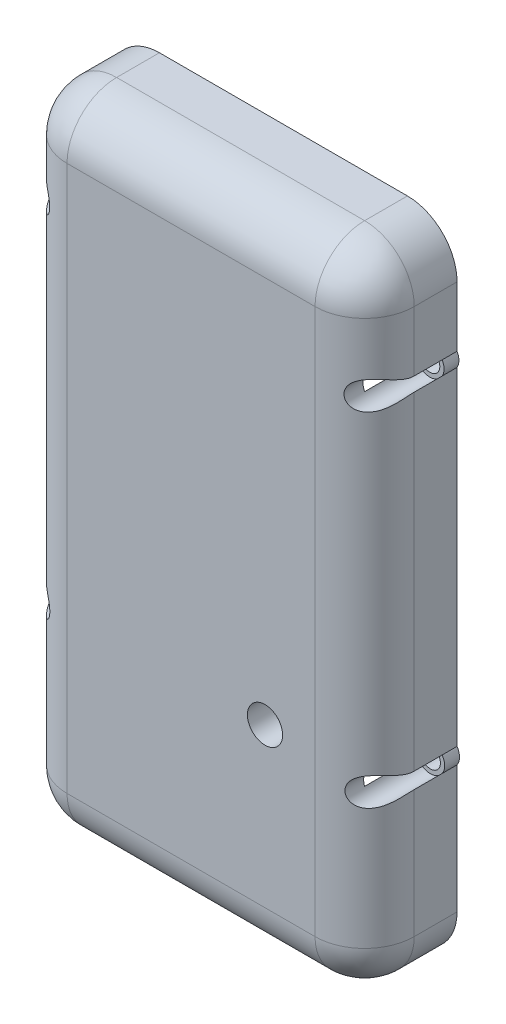
from build123d import *

# Parameters (mm, degrees)
SKETCH1_W           = 70
SKETCH1_H           = 130
BOSS_EXTRUDE1_DEPTH = 18.631112222
SHELL1_T            = -5
FILLET1_R           = 10
FILLET2_R           = 10
FILLET4_R           = 10
FILLET6_R           = 10
SKETCH2_R           = 3.55
CUT_EXTRUDE1_DEPTH  = 26
SKETCH3_W           = 14.110384164
SKETCH3_H           = 8.306919709
CUT_EXTRUDE4_DEPTH  = 30
SKETCH4_R           = 2.85
CUT_EXTRUDE5_DEPTH  = 24
SKETCH5_R           = 2.85
SKETCH5_R_2         = 2
BOSS_EXTRUDE2_DEPTH = 3


with BuildPart() as part:
    # Sketch1 → Boss-Extrude1 (new body)
    with BuildSketch(Plane.XY):
        with Locations((8.736165571, -22.960828507)):
            Rectangle(SKETCH1_W, SKETCH1_H)
    extrude(amount=BOSS_EXTRUDE1_DEPTH)

    # Shell1
    shell1_openings = [part.faces().sort_by_distance(p)[0] for p in [
        (8.736165571, -22.960828507, 0),
    ]]
    offset(amount=SHELL1_T, openings=shell1_openings, kind=Kind.INTERSECTION)

    # Fillet1
    fillet1_edges = [part.edges().sort_by_distance(p)[0] for p in [
        (-26.263834429, -22.960828507, 18.631112222),
    ]]
    fillet(fillet1_edges, radius=FILLET1_R)

    # Fillet2
    fillet2_edges = [part.edges().sort_by_distance(p)[0] for p in [
        (43.736165571, -22.960828507, 18.631112222),
    ]]
    fillet(fillet2_edges, radius=FILLET2_R)

    # Fillet4
    fillet4_edges = [part.edges().sort_by_distance(p)[0] for p in [
        (-26.263834429, 42.039171493, 4.315556111),
        (-23.334902241, 42.039171493, 15.702180034),
        (8.736165571, 42.039171493, 18.631112222),
        (43.736165571, 42.039171493, 4.315556111),
        (40.807233383, 42.039171493, 15.702180034),
    ]]
    fillet(fillet4_edges, radius=FILLET4_R)

    # Fillet6
    fillet6_edges = [part.edges().sort_by_distance(p)[0] for p in [
        (8.736165571, -87.960828507, 18.631112222),
        (-26.263834429, -87.960828507, 4.315556111),
        (-23.334902241, -87.960828507, 15.702180034),
        (43.736165571, -87.960828507, 4.315556111),
        (40.807233383, -87.960828507, 15.702180034),
    ]]
    fillet(fillet6_edges, radius=FILLET6_R)

    # Sketch2 → Cut-Extrude1 (cut)
    with BuildSketch(Plane.XY.offset(7.783233926)):
        with Locations((23.655578881, -46.034025118)):
            Circle(SKETCH2_R)
    extrude(amount=CUT_EXTRUDE1_DEPTH, mode=Mode.SUBTRACT)

    # Sketch3 → Cut-Extrude4 (cut)
    with BuildSketch(Plane(origin=(1.2837e-05, -73.41928233, 3.209e-06), x_dir=(-1, -1.75e-07, 0), z_dir=(1.75e-07, -1, 4.4e-08))):
        with Locations((-5.237013871, -5.398091498)):
            Rectangle(SKETCH3_W, SKETCH3_H)
    extrude(amount=CUT_EXTRUDE4_DEPTH, mode=Mode.SUBTRACT)

    # Sketch4 → Cut-Extrude5 (cut)
    with BuildSketch(Plane.XY):
        with Locations((41.386116272, -50.678340094)):
            Circle(SKETCH4_R)
        with Locations((41.259820466, 18.511183857)):
            Circle(SKETCH4_R)
        with Locations((-23.693524603, -49.042382464)):
            Circle(SKETCH4_R)
        with Locations((-23.751261028, 21.516382028)):
            Circle(SKETCH4_R)
    extrude(amount=CUT_EXTRUDE5_DEPTH, mode=Mode.SUBTRACT)

    # Sketch5 → Boss-Extrude2 (add)
    with BuildSketch(Plane.XY):
        with Locations((-23.751261028, 21.516382028)):
            Circle(SKETCH5_R)
        with Locations((-23.751261028, 21.516382028)):
            Circle(SKETCH5_R_2, mode=Mode.SUBTRACT)
        with Locations((41.259820466, 18.511183857)):
            Circle(SKETCH5_R)
        with Locations((41.259820466, 18.511183857)):
            Circle(SKETCH5_R_2, mode=Mode.SUBTRACT)
        with Locations((41.386116272, -50.678340094)):
            Circle(SKETCH5_R)
        with Locations((41.386116272, -50.678340094)):
            Circle(SKETCH5_R_2, mode=Mode.SUBTRACT)
        with Locations((-23.693524603, -49.042382464)):
            Circle(SKETCH5_R)
        with Locations((-23.693524603, -49.042382464)):
            Circle(SKETCH5_R_2, mode=Mode.SUBTRACT)
    extrude(amount=BOSS_EXTRUDE2_DEPTH)


solid = part.part
